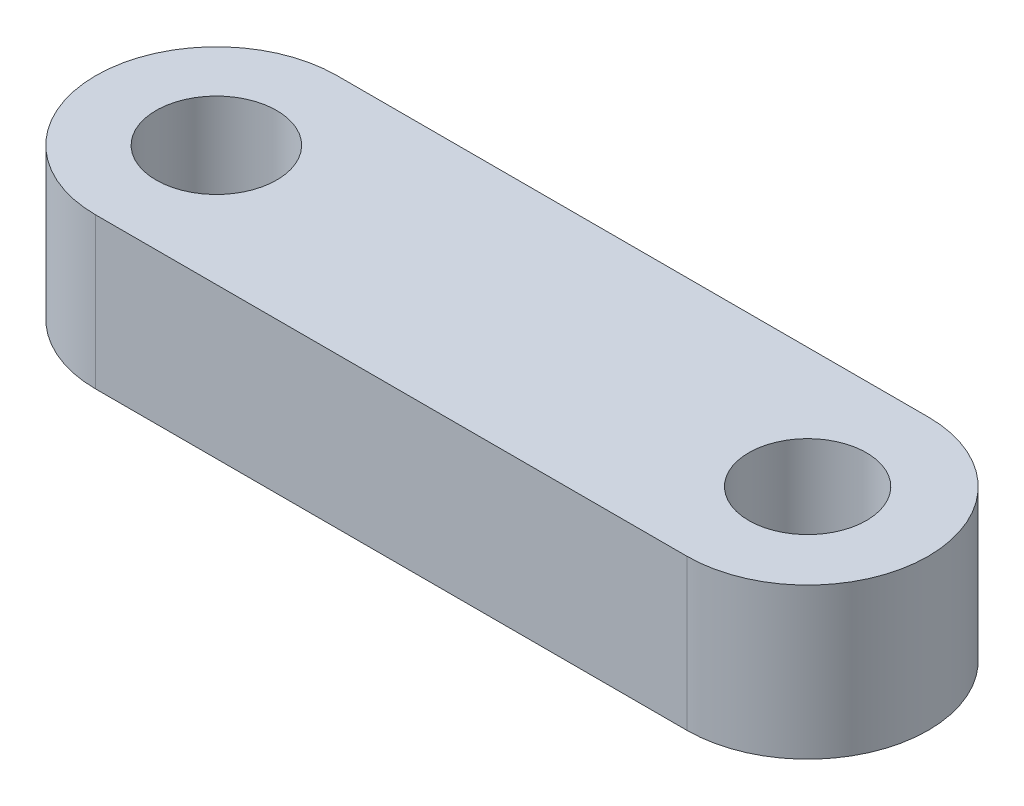
from build123d import *

# Parameters (mm, degrees)
SKETCH_1_R      = 2
SKETCH_1_R_2    = 1.95
EXTRUDE_1_DEPTH = 5


with BuildPart() as part:
    # 草图1 → 凸台-拉伸1 (new body)
    with BuildSketch(Plane(origin=(0, 0, 0), x_dir=(1, 0, 0), z_dir=(0, 1, 0))):
        with BuildLine():
            Line((0, 4), (19.604, 4))
            ThreePointArc((19.604, 4), (23.604, 0), (19.604, -4))
            Line((19.604, -4), (0, -4))
            ThreePointArc((0, -4), (-4, 0), (0, 4))
        make_face()
        Circle(SKETCH_1_R, mode=Mode.SUBTRACT)
        with Locations((19.604, 0)):
            Circle(SKETCH_1_R_2, mode=Mode.SUBTRACT)
    extrude(amount=EXTRUDE_1_DEPTH)


solid = part.part
